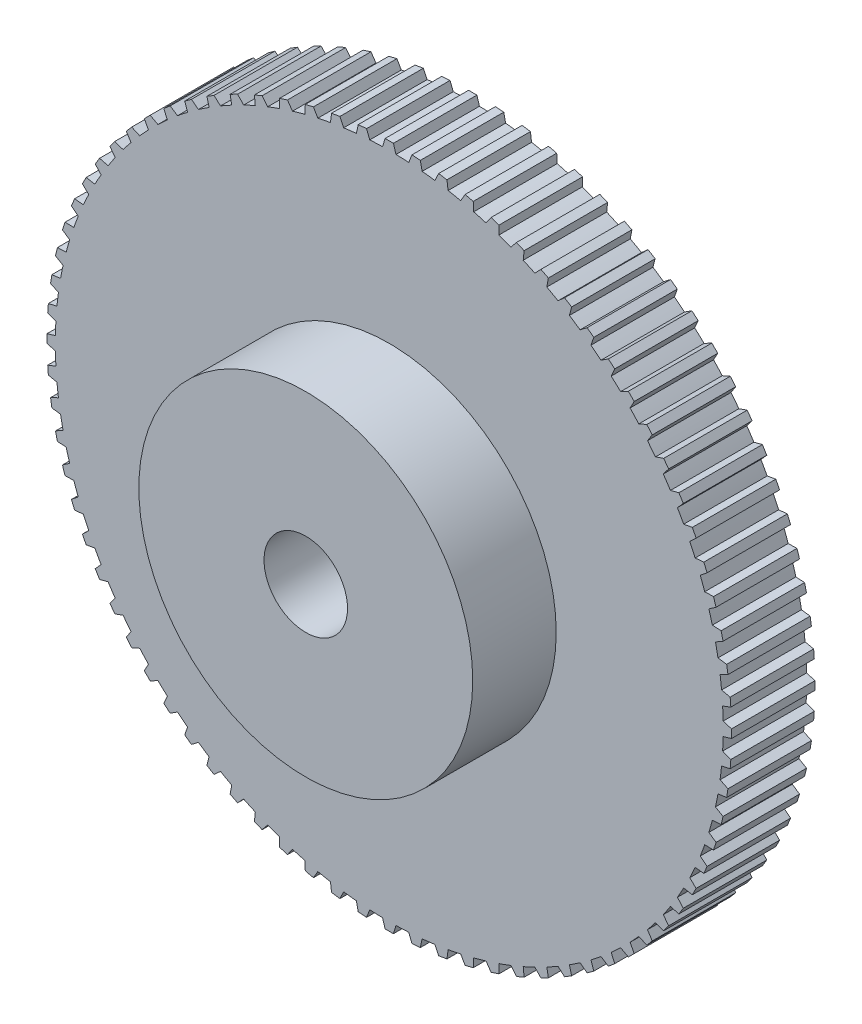
from build123d import *

# Parameters (mm, degrees)
SKETCH_1_R               = 40
EXTRUDE_1_DEPTH          = 10
SKETCH_2_R               = 20
EXTRUDE_2_DEPTH          = 10
SKETCH_3_R               = 5
CUT_EXTRUDE_1_DEPTH      = 21
EXTRUDE_3_DEPTH          = 10
PATTERN_CIRCULAR_1_COUNT = 80


with BuildPart() as part:
    # 草圖1 → 填料-伸長1 (new body)
    with BuildSketch(Plane.XY):
        Circle(SKETCH_1_R)
    extrude(amount=EXTRUDE_1_DEPTH)

    # 草圖2 → 填料-伸長2 (add)
    with BuildSketch(Plane.XY.offset(10)):
        Circle(SKETCH_2_R)
    extrude(amount=EXTRUDE_2_DEPTH)

    # 草圖3 → 除料-伸長1 (cut, through all)
    with BuildSketch(Plane.XY.offset(20)):
        Circle(SKETCH_3_R)
    extrude(amount=-CUT_EXTRUDE_1_DEPTH, mode=Mode.SUBTRACT)

    # 草圖4 → 填料-伸長3 (add)
    with BuildSketch(Plane.XY.offset(10)):
        Polygon((-2, 36), (2, 36), (0.5, 41), (-0.5, 41), align=None)
    extrude_3 = extrude(amount=-EXTRUDE_3_DEPTH)

    # 環狀複製排列1: 填料-伸長3 ×80 about axis
    pattern_circular_1_axis = Axis((0, 0, 0), (0, 0, 1))
    for i in range(1, PATTERN_CIRCULAR_1_COUNT):
        add(extrude_3.rotate(pattern_circular_1_axis, i * 360 / PATTERN_CIRCULAR_1_COUNT))


solid = part.part
